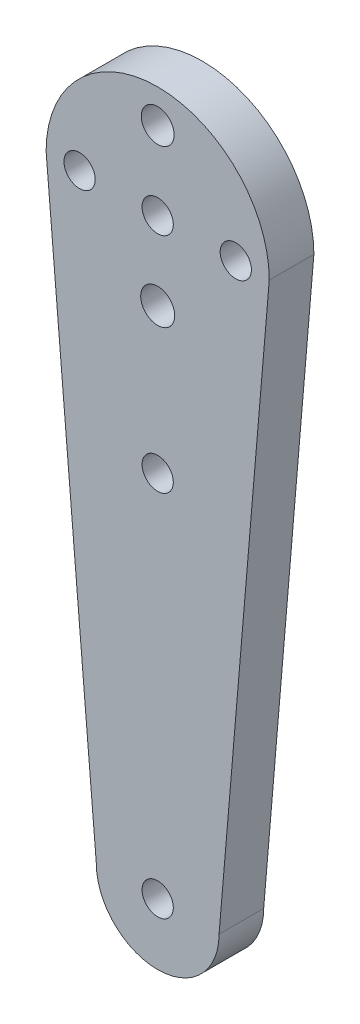
from build123d import *

# Parameters (mm, degrees)
SKETCH1_R           = 1.4
BOSS_EXTRUDE1_DEPTH = 4
SKETCH2_R           = 1.521670414
SKETCH2_R_2         = 1.472584271
CUT_EXTRUDE1_DEPTH  = 10
SKETCH3_R           = 1.4
CUT_EXTRUDE2_DEPTH  = 10


with BuildPart() as part:
    # Sketch1 → Boss-Extrude1 (new body)
    with BuildSketch(Plane.XY):
        with BuildLine():
            Line((-15.500688459, 45.016091721), (-11.000688459, -8.006682704))
            ThreePointArc((-11.000688459, -8.006682704), (-5.500688459, -13.506682704), (-0.000688459, -8.006682704))
            Line((-0.000688459, -8.006682704), (4.499311541, 45.016091721))
            ThreePointArc((4.499311541, 45.016091721), (-5.500688459, 55.016091721), (-15.500688459, 45.016091721))
        make_face()
        with Locations((-5.500688459, -8.006682704)):
            Circle(SKETCH1_R, mode=Mode.SUBTRACT)
        with Locations((-5.500688459, 45.016091721)):
            Circle(SKETCH1_R, mode=Mode.SUBTRACT)
        with Locations((1.499311541, 45.016091721)):
            Circle(SKETCH1_R, mode=Mode.SUBTRACT)
        with Locations((-12.500688459, 45.016091721)):
            Circle(SKETCH1_R, mode=Mode.SUBTRACT)
    extrude(amount=BOSS_EXTRUDE1_DEPTH)

    # Sketch2 → Cut-Extrude1 (cut)
    with BuildSketch(Plane.XY.offset(4)):
        with Locations((-5.500688459, 38.016091721)):
            Circle(SKETCH2_R)
        with Locations((-5.500688459, 52.016091721)):
            Circle(SKETCH2_R_2)
    extrude(amount=-CUT_EXTRUDE1_DEPTH, mode=Mode.SUBTRACT)

    # Sketch3 → Cut-Extrude2 (cut)
    with BuildSketch(Plane.XY.offset(4)):
        with Locations((-5.500688459, 25.016091721)):
            Circle(SKETCH3_R)
    extrude(amount=-CUT_EXTRUDE2_DEPTH, mode=Mode.SUBTRACT)


solid = part.part
